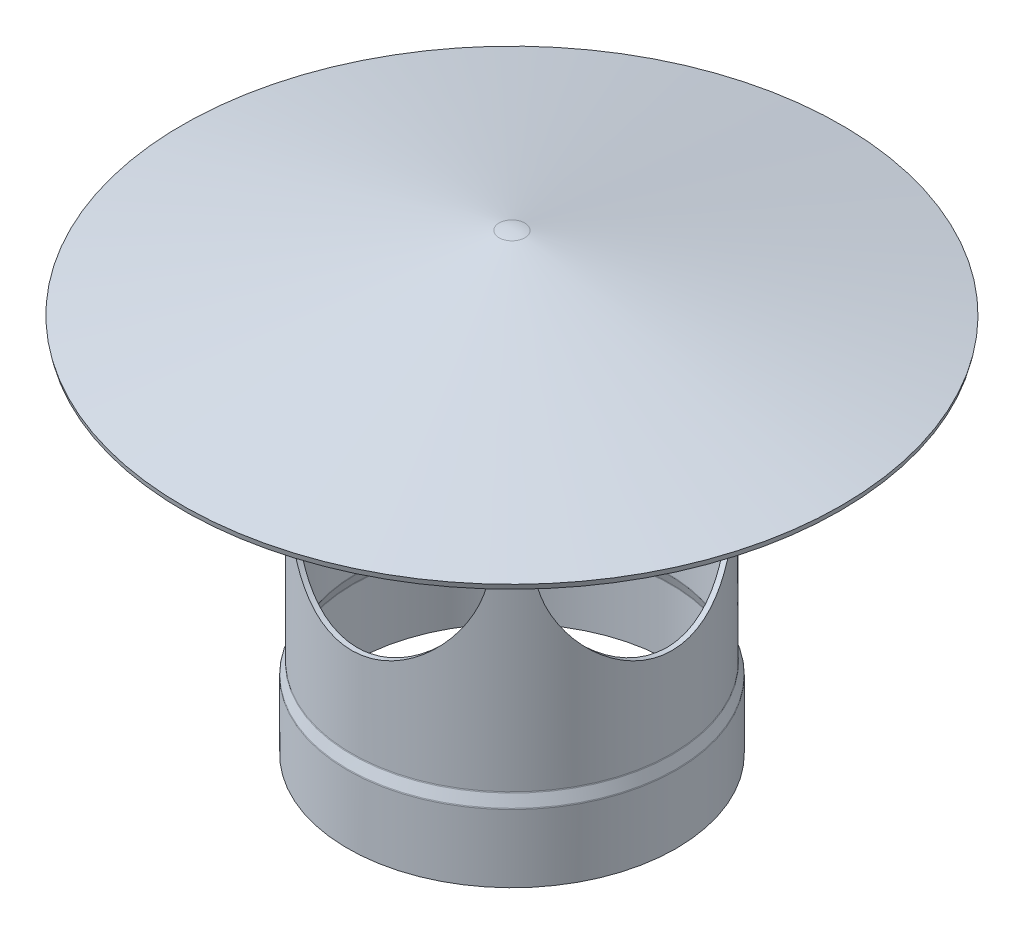
from build123d import *

# Parameters (mm, degrees)
CUT_EXTRUDE1_REACH             = 834.535
SKETCH2_RX                     = 120.65
SKETCH2_RY                     = 113.50625
CUT_EXTRUDE1_DIRECTION_2_DEPTH = 50.8
CIRPATTERN1_COUNT              = 4
FILLET3_R                      = 3.175


with BuildPart() as part:
    # Sketch1 → Revolve1 (revolve)
    with BuildSketch(Plane.XY, mode=Mode.PRIVATE) as revolve1_sk:
        with BuildLine():
            Line((-183.642, 0), (-183.642, 76.2))
            Line((-183.642, 76.2), (-178.8795, 88.9))
            Line((-178.8795, 88.9), (-178.8795, 462.194851105))
            Line((-178.8795, 462.194851105), (-366.979902023, 418.561839824))
            Line((-366.979902023, 418.561839824), (-368.3, 424.252736531))
            Line((-368.3, 424.252736531), (-14.348891057, 506.357572903))
            ThreePointArc((-14.348891057, 506.357572903), (-7.221292151, 507.588057029), (0, 508))
            Line((0, 508), (0, 503.688921068))
            Line((0, 503.688921068), (-160.93929566, 466.356379363))
            Line((-160.93929566, 466.356379363), (0, 423.232825061))
            Line((0, 423.232825061), (0, 417.632749106))
            ThreePointArc((0, 417.632749106), (-1.657682641, 417.741399366), (-3.287001873, 418.065491112))
            Line((-3.287001873, 418.065491112), (-173.0375, 463.55))
            Line((-173.0375, 463.55), (-173.0375, 87.840643373))
            Line((-173.0375, 87.840643373), (-177.8, 75.140643373))
            Line((-177.8, 75.140643373), (-177.8, 0))
            Line((-177.8, 0), (-183.642, 0))
        make_face()
    revolve(revolve1_sk.sketch.rotate(Axis((0, -82.737615653, 0), (0, 1, 0)), 180), axis=Axis((0, -82.737615653, 0), (0, 1, 0)))

    # Sketch2 → Cut-Extrude1 (cut, up to next)
    with BuildSketch(Plane.XY.offset(178.8795), mode=Mode.PRIVATE) as cut_extrude1_sk1:
        with Locations(Location((0, 309.794851105), (0, 0, -90))):
            Ellipse(SKETCH2_RX, SKETCH2_RY)
    cut_extrude1_tool1 = extrude(cut_extrude1_sk1.sketch, amount=-CUT_EXTRUDE1_REACH, mode=Mode.PRIVATE) & part.part
    cut_extrude1 = cut_extrude1_tool1.solids().sort_by_distance((0, 309.794851, 178.8795))[0]
    add(cut_extrude1, mode=Mode.SUBTRACT)

    # Sketch2 → Cut-Extrude1 direction 2 (cut)
    with BuildSketch(Plane.XY.offset(178.8795)):
        with Locations(Location((0, 309.794851105), (0, 0, -90))):
            Ellipse(SKETCH2_RX, SKETCH2_RY)
    cut_extrude1_direction_2 = extrude(amount=CUT_EXTRUDE1_DIRECTION_2_DEPTH, mode=Mode.SUBTRACT)

    # CirPattern1: Cut-Extrude1, Cut-Extrude1 direction 2 ×4 about axis
    cirpattern1_axis = Axis((0, -82.737615653, 0), (0, -1, 0))
    add([cut_extrude1.rotate(cirpattern1_axis, i * 360 / CIRPATTERN1_COUNT) for i in range(1, CIRPATTERN1_COUNT)], mode=Mode.SUBTRACT)
    add([cut_extrude1_direction_2.rotate(cirpattern1_axis, i * 360 / CIRPATTERN1_COUNT) for i in range(1, CIRPATTERN1_COUNT)], mode=Mode.SUBTRACT)

    # Fillet3
    fillet3_edges = [part.edges().sort_by_distance(p)[0] for p in [
        (-183.642, 76.2, 0),
        (-178.8795, 88.9, 0),
        (-173.0375, 87.840643373, 0),
        (-177.8, 75.140643373, 0),
    ]]
    fillet(fillet3_edges, radius=FILLET3_R)


solid = part.part
